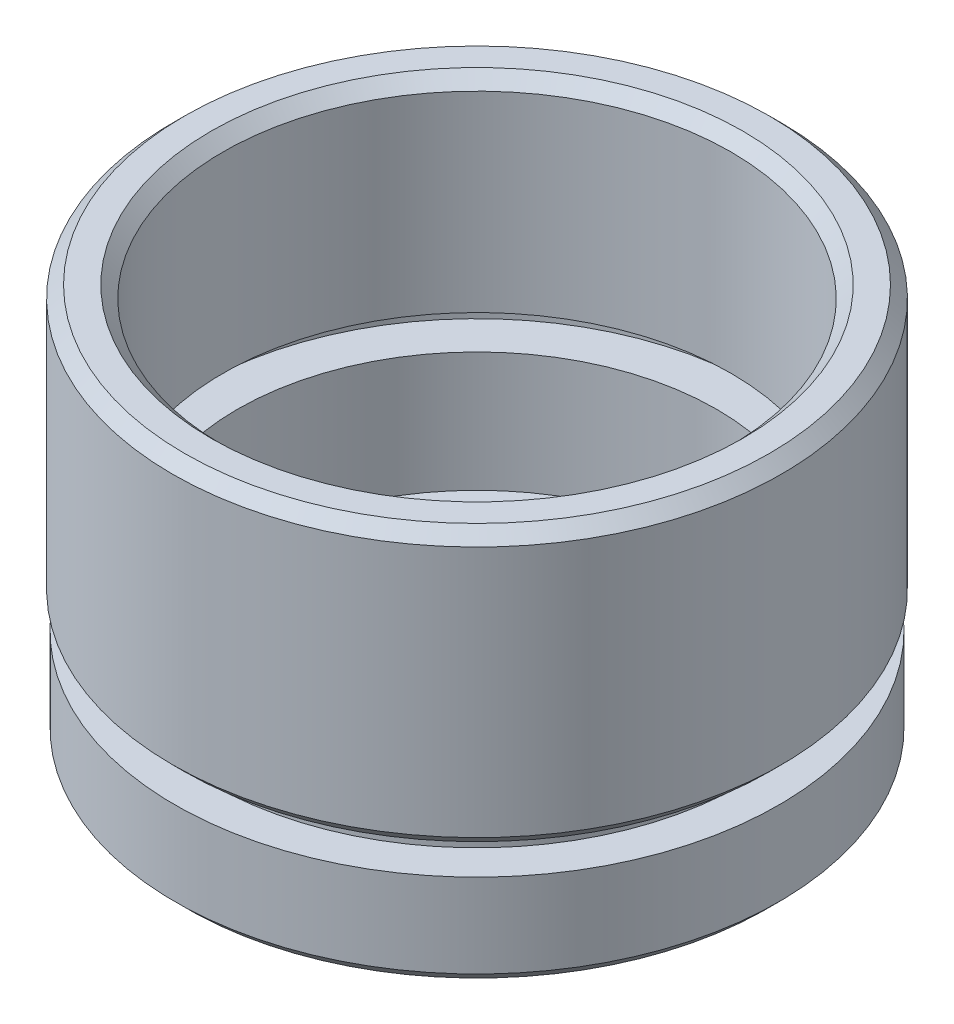
from build123d import *

# Parameters (mm, degrees)
CHAMFER_1_SIZE = 0.5


with BuildPart() as part:
    # 草图1 → 旋转1 (revolve)
    with BuildSketch(Plane.XY, mode=Mode.PRIVATE) as revolve_1_sk:
        Polygon((9.25, 0), (12.6, 0), (12.6, 4), (11.1, 4), (11.1, 5), (12.7, 5), (12.7, 16.5), (10.6, 16.5), (10.6, 8), (11.7, 8), (11.7, 7), (10, 7), (10, 2), (9.25, 2), align=None)
    revolve(revolve_1_sk.sketch.rotate(Axis((0, 0, 0), (0, 1, 0)), 90), axis=Axis((0, 0, 0), (0, 1, 0)))  # turned: the seam where the file's is

    # 倒角1
    chamfer_1_edges = [part.edges().sort_by_distance(p)[0] for p in [
        (0, 16.5, 10.6),
        (0, 16.5, 12.7),
        (0, 5, 12.7),
        (0, 0, 12.6),
    ]]
    chamfer(chamfer_1_edges, length=CHAMFER_1_SIZE)


solid = part.part
